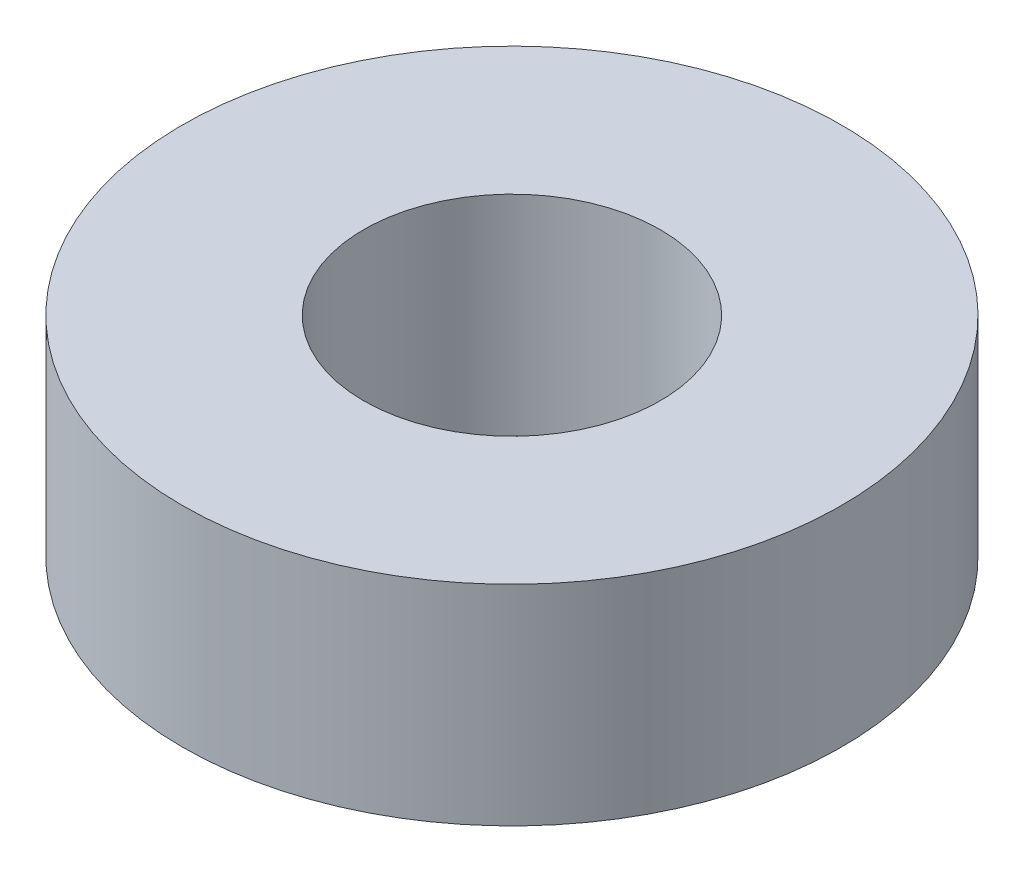
from build123d import *

# Parameters (mm, degrees)
SKETCH1_R           = 5
SKETCH1_R_2         = 2.25
BOSS_EXTRUDE1_DEPTH = 3.175


with BuildPart() as part:
    # Sketch1 → Boss-Extrude1 (new body)
    with BuildSketch(Plane(origin=(0, 0, 0), x_dir=(1, 0, 0), z_dir=(0, 1, 0))):
        Circle(SKETCH1_R)
        Circle(SKETCH1_R_2, mode=Mode.SUBTRACT)
    extrude(amount=BOSS_EXTRUDE1_DEPTH)


solid = part.part
